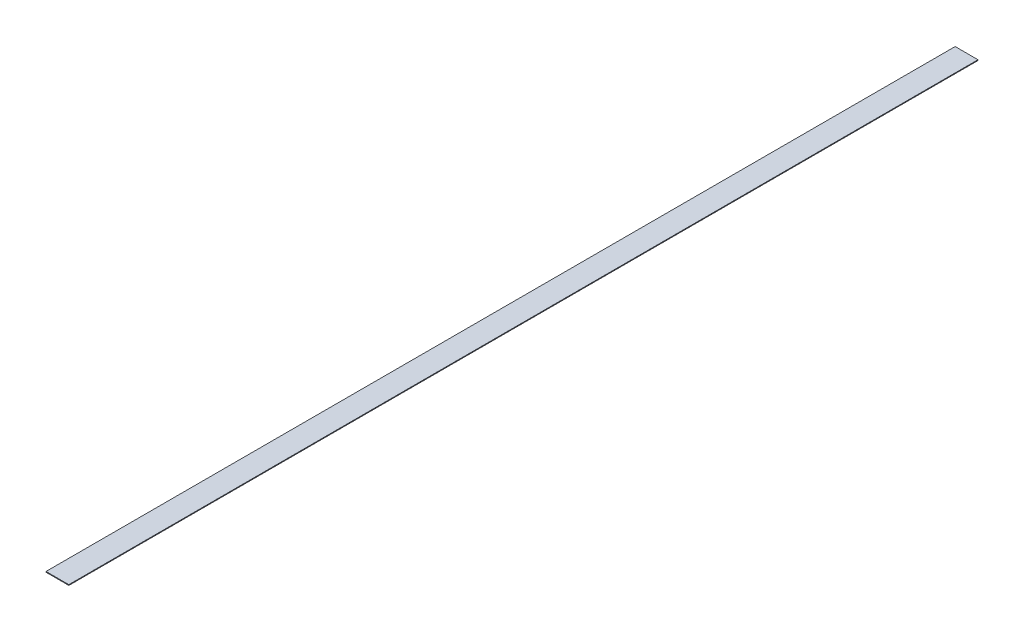
from build123d import *

# Parameters (mm, degrees)
SKETCH1_W           = 50.8
SKETCH1_H           = 2022.475
BOSS_EXTRUDE1_DEPTH = 1.5875


with BuildPart() as part:
    # Sketch1 → Boss-Extrude1 (new body)
    with BuildSketch(Plane(origin=(0, 0, 0), x_dir=(1, 0, 0), z_dir=(0, 1, 0))):
        Rectangle(SKETCH1_W, SKETCH1_H)
    extrude(amount=BOSS_EXTRUDE1_DEPTH)


solid = part.part
